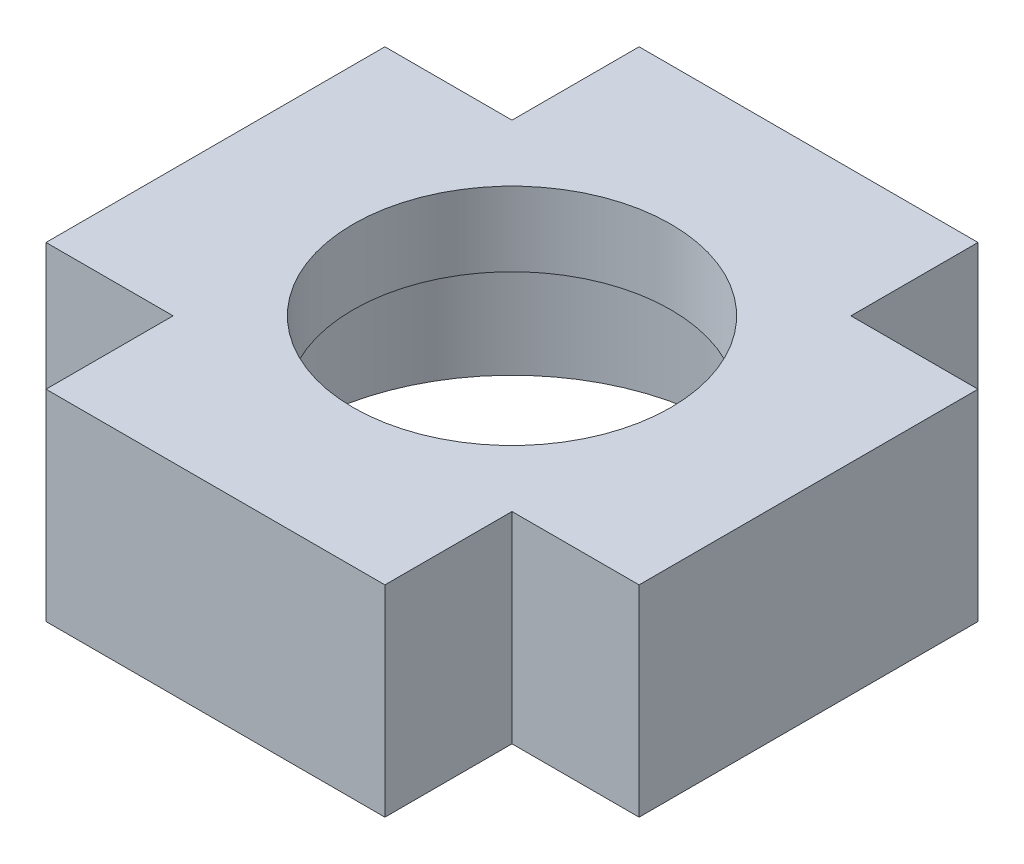
from build123d import *

# Parameters (mm, degrees)
SKETCH_1_R          = 7.5
EXTRUDE_1_DEPTH     = 9.5
SKETCH_2_R          = 10
CUT_EXTRUDE_1_DEPTH = 6


with BuildPart() as part:
    # 草图1 → 凸台-拉伸1 (new body)
    with BuildSketch(Plane(origin=(0, 0, 0), x_dir=(1, 0, 0), z_dir=(0, 1, 0))):
        Polygon((-8, 14), (8, 14), (8, 8), (14, 8), (14, -8), (8, -8), (8, -14), (-8, -14), (-8, -8), (-14, -8), (-14, 8), (-8, 8), align=None)
        Circle(SKETCH_1_R, mode=Mode.SUBTRACT)
    extrude(amount=EXTRUDE_1_DEPTH)

    # 草图2 → 切除-拉伸1 (cut)
    with BuildSketch(Plane.XZ):
        Circle(SKETCH_2_R)
    extrude(amount=-CUT_EXTRUDE_1_DEPTH, mode=Mode.SUBTRACT)


solid = part.part
